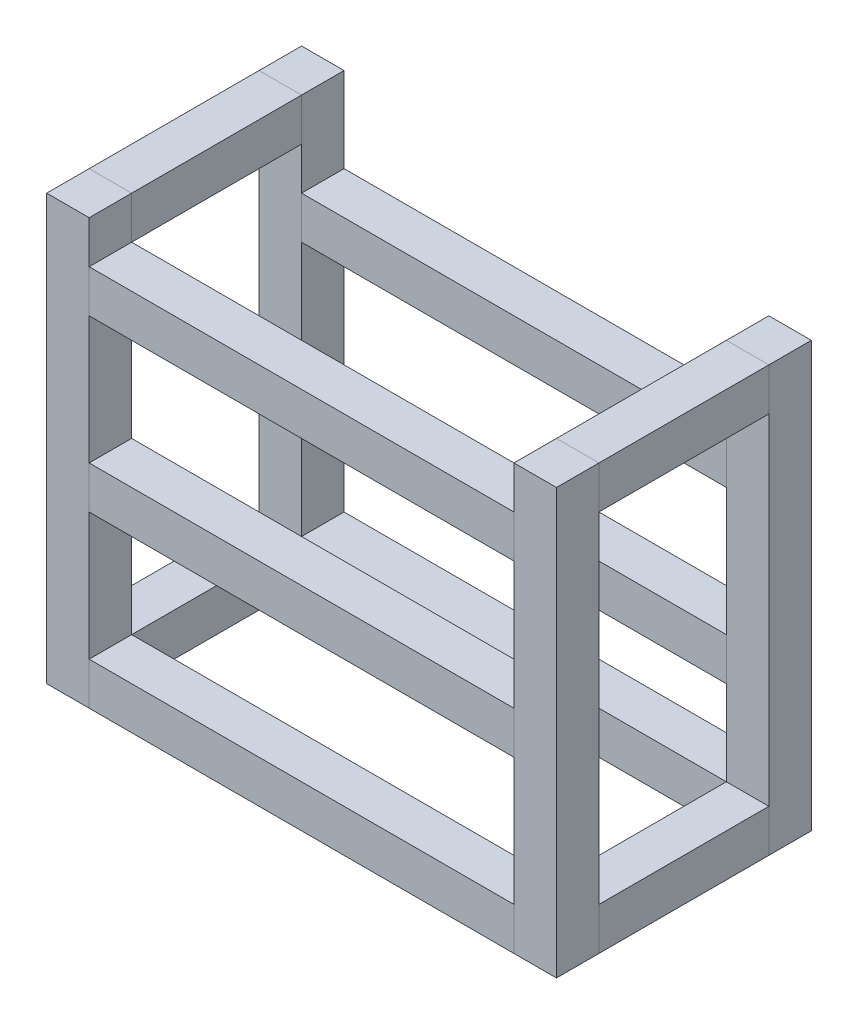
from build123d import *

# Parameters (mm, degrees)
SKETCH1_W                  = 25.4
SKETCH1_H                  = 25.4
BOSS_EXTRUDE1_DEPTH        = 254
BOSS_EXTRUDE1_2_DEPTH      = 254
BOSS_EXTRUDE1_3_DEPTH      = 254
BOSS_EXTRUDE1_4_DEPTH      = 254
SKETCH2_W                  = 25.4
SKETCH2_H                  = 25.4
BOSS_EXTRUDE2_DEPTH        = 127
BOSS_EXTRUDE2_DEPTH_BACK   = 127
BOSS_EXTRUDE2_2_DEPTH      = 127
BOSS_EXTRUDE2_2_DEPTH_BACK = 127
BOSS_EXTRUDE2_3_DEPTH      = 127
BOSS_EXTRUDE2_3_DEPTH_BACK = 127
BOSS_EXTRUDE2_4_DEPTH      = 127
BOSS_EXTRUDE2_4_DEPTH_BACK = 127
BOSS_EXTRUDE2_5_DEPTH      = 127
BOSS_EXTRUDE2_5_DEPTH_BACK = 127
BOSS_EXTRUDE2_6_DEPTH      = 127
BOSS_EXTRUDE2_6_DEPTH_BACK = 127
SKETCH3_W                  = 25.4
SKETCH3_H                  = 25.4
BOSS_EXTRUDE3_DEPTH        = 50.8
BOSS_EXTRUDE3_DEPTH_BACK   = 50.8
BOSS_EXTRUDE3_2_DEPTH      = 50.8
BOSS_EXTRUDE3_2_DEPTH_BACK = 50.8
BOSS_EXTRUDE3_3_DEPTH      = 50.8
BOSS_EXTRUDE3_3_DEPTH_BACK = 50.8
BOSS_EXTRUDE3_4_DEPTH      = 50.8
BOSS_EXTRUDE3_4_DEPTH_BACK = 50.8


with BuildPart() as part:
    # Sketch1 → Boss-Extrude1 (new body)
    with BuildSketch(Plane(origin=(0, 0, 0), x_dir=(1, 0, 0), z_dir=(0, 1, 0))):
        with Locations((-139.7, 63.5)):
            Rectangle(SKETCH1_W, SKETCH1_H)
    extrude(amount=BOSS_EXTRUDE1_DEPTH)


with BuildPart() as body_2:
    # Sketch1 → Boss-Extrude1 2 (new body)
    with BuildSketch(Plane(origin=(0, 0, 0), x_dir=(1, 0, 0), z_dir=(0, 1, 0))):
        with Locations((-139.7, -63.5)):
            Rectangle(SKETCH1_W, SKETCH1_H)
    extrude(amount=BOSS_EXTRUDE1_2_DEPTH)


with BuildPart() as body_3:
    # Sketch1 → Boss-Extrude1 3 (new body)
    with BuildSketch(Plane(origin=(0, 0, 0), x_dir=(1, 0, 0), z_dir=(0, 1, 0))):
        with Locations((139.7, -63.5)):
            Rectangle(SKETCH1_W, SKETCH1_H)
    extrude(amount=BOSS_EXTRUDE1_3_DEPTH)


with BuildPart() as body_4:
    # Sketch1 → Boss-Extrude1 4 (new body)
    with BuildSketch(Plane(origin=(0, 0, 0), x_dir=(1, 0, 0), z_dir=(0, 1, 0))):
        with Locations((139.7, 63.5)):
            Rectangle(SKETCH1_W, SKETCH1_H)
    extrude(amount=BOSS_EXTRUDE1_4_DEPTH)


with BuildPart() as body_5:
    # Sketch2 → Boss-Extrude2 (new body, two sides)
    with BuildSketch(Plane(origin=(0, 0, 0), x_dir=(0, 0, -1), z_dir=(1, 0, 0))) as boss_extrude2_sk:
        with Locations((-63.5, 215.9)):
            Rectangle(SKETCH2_W, SKETCH2_H)
    extrude(amount=BOSS_EXTRUDE2_DEPTH)
    extrude(boss_extrude2_sk.sketch, amount=-BOSS_EXTRUDE2_DEPTH_BACK)


with BuildPart() as body_6:
    # Sketch2 → Boss-Extrude2 2 (new body, two sides)
    with BuildSketch(Plane(origin=(0, 0, 0), x_dir=(0, 0, -1), z_dir=(1, 0, 0))) as boss_extrude2_2_sk:
        with Locations((63.5, 190.5)):
            Rectangle(SKETCH2_W, SKETCH2_H)
    extrude(amount=BOSS_EXTRUDE2_2_DEPTH)
    extrude(boss_extrude2_2_sk.sketch, amount=-BOSS_EXTRUDE2_2_DEPTH_BACK)


with BuildPart() as body_7:
    # Sketch2 → Boss-Extrude2 3 (new body, two sides)
    with BuildSketch(Plane(origin=(0, 0, 0), x_dir=(0, 0, -1), z_dir=(1, 0, 0))) as boss_extrude2_3_sk:
        with Locations((-63.5, 12.7)):
            Rectangle(SKETCH2_W, SKETCH2_H)
    extrude(amount=BOSS_EXTRUDE2_3_DEPTH)
    extrude(boss_extrude2_3_sk.sketch, amount=-BOSS_EXTRUDE2_3_DEPTH_BACK)


with BuildPart() as body_8:
    # Sketch2 → Boss-Extrude2 4 (new body, two sides)
    with BuildSketch(Plane(origin=(0, 0, 0), x_dir=(0, 0, -1), z_dir=(1, 0, 0))) as boss_extrude2_4_sk:
        with Locations((63.5, 12.7)):
            Rectangle(SKETCH2_W, SKETCH2_H)
    extrude(amount=BOSS_EXTRUDE2_4_DEPTH)
    extrude(boss_extrude2_4_sk.sketch, amount=-BOSS_EXTRUDE2_4_DEPTH_BACK)


with BuildPart() as body_9:
    # Sketch2 → Boss-Extrude2 5 (new body, two sides)
    with BuildSketch(Plane(origin=(0, 0, 0), x_dir=(0, 0, -1), z_dir=(1, 0, 0))) as boss_extrude2_5_sk:
        with Locations((-63.5, 114.3)):
            Rectangle(SKETCH2_W, SKETCH2_H)
    extrude(amount=BOSS_EXTRUDE2_5_DEPTH)
    extrude(boss_extrude2_5_sk.sketch, amount=-BOSS_EXTRUDE2_5_DEPTH_BACK)


with BuildPart() as body_10:
    # Sketch2 → Boss-Extrude2 6 (new body, two sides)
    with BuildSketch(Plane(origin=(0, 0, 0), x_dir=(0, 0, -1), z_dir=(1, 0, 0))) as boss_extrude2_6_sk:
        with Locations((63.5, 88.9)):
            Rectangle(SKETCH2_W, SKETCH2_H)
    extrude(amount=BOSS_EXTRUDE2_6_DEPTH)
    extrude(boss_extrude2_6_sk.sketch, amount=-BOSS_EXTRUDE2_6_DEPTH_BACK)


with BuildPart() as body_11:
    # Sketch3 → Boss-Extrude3 (new body, two sides)
    with BuildSketch(Plane.XY) as boss_extrude3_sk:
        with Locations((-139.7, 241.3)):
            Rectangle(SKETCH3_W, SKETCH3_H)
    extrude(amount=BOSS_EXTRUDE3_DEPTH)
    extrude(boss_extrude3_sk.sketch, amount=-BOSS_EXTRUDE3_DEPTH_BACK)


with BuildPart() as body_12:
    # Sketch3 → Boss-Extrude3 2 (new body, two sides)
    with BuildSketch(Plane.XY) as boss_extrude3_2_sk:
        with Locations((-139.7, 12.7)):
            Rectangle(SKETCH3_W, SKETCH3_H)
    extrude(amount=BOSS_EXTRUDE3_2_DEPTH)
    extrude(boss_extrude3_2_sk.sketch, amount=-BOSS_EXTRUDE3_2_DEPTH_BACK)


with BuildPart() as body_13:
    # Sketch3 → Boss-Extrude3 3 (new body, two sides)
    with BuildSketch(Plane.XY) as boss_extrude3_3_sk:
        with Locations((139.7, 241.3)):
            Rectangle(SKETCH3_W, SKETCH3_H)
    extrude(amount=BOSS_EXTRUDE3_3_DEPTH)
    extrude(boss_extrude3_3_sk.sketch, amount=-BOSS_EXTRUDE3_3_DEPTH_BACK)


with BuildPart() as body_14:
    # Sketch3 → Boss-Extrude3 4 (new body, two sides)
    with BuildSketch(Plane.XY) as boss_extrude3_4_sk:
        with Locations((139.7, 12.7)):
            Rectangle(SKETCH3_W, SKETCH3_H)
    extrude(amount=BOSS_EXTRUDE3_4_DEPTH)
    extrude(boss_extrude3_4_sk.sketch, amount=-BOSS_EXTRUDE3_4_DEPTH_BACK)


solid = Compound([part.part, body_2.part, body_3.part, body_4.part, body_5.part, body_6.part, body_7.part, body_8.part, body_9.part, body_10.part, body_11.part, body_12.part, body_13.part, body_14.part])
